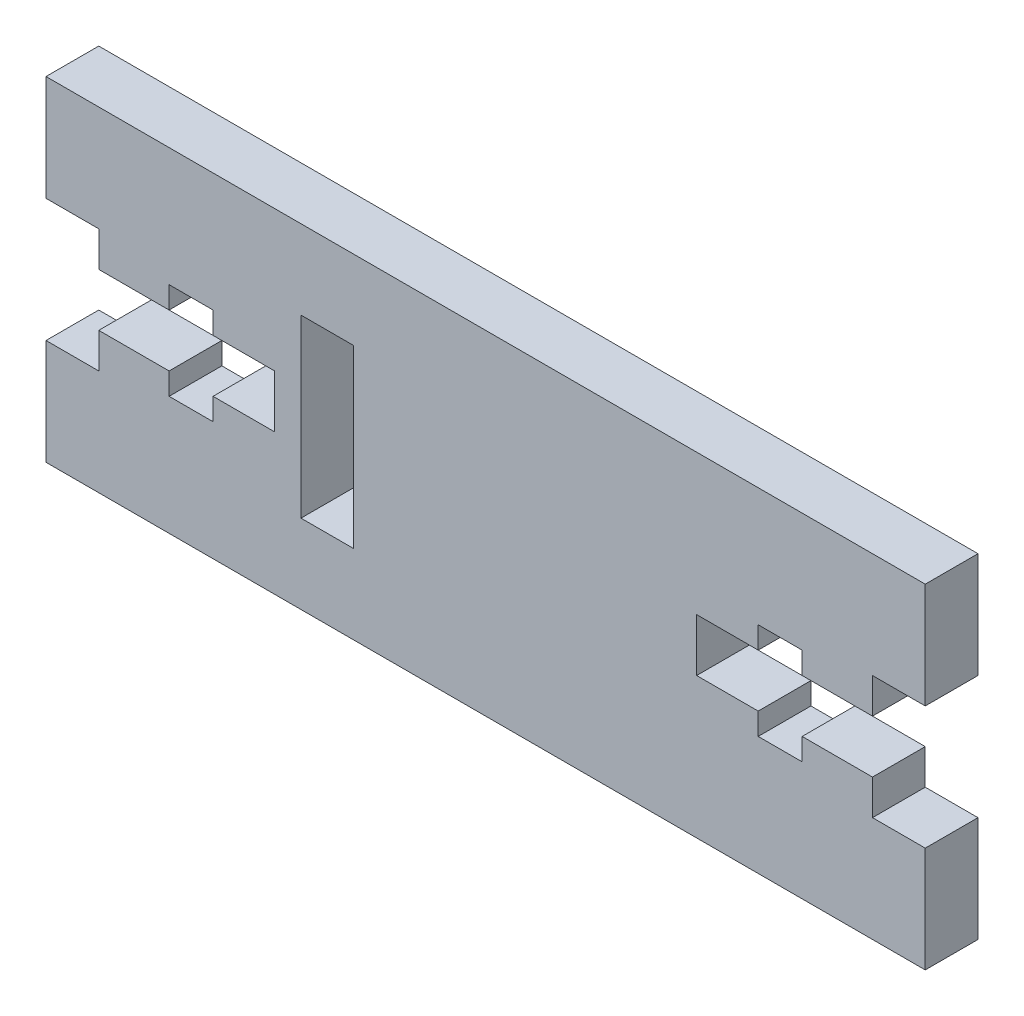
from build123d import *

# Parameters (mm, degrees)
MODEL_W             = 3
MODEL_H             = 10
BOSS_EXTRUDE1_DEPTH = 3


with BuildPart() as part:
    # Model → Boss-Extrude1 (new body)
    with BuildSketch(Plane.XY):
        Polygon((83, 32.5), (33, 32.5), (33, 38.5), (36, 38.5), (36, 40.5), (40, 40.5), (40, 39.25), (42.5, 39.25), (42.5, 40.5), (46, 40.5), (46, 43.5), (42.5, 43.5), (42.5, 44.75), (40, 44.75), (40, 43.5), (36, 43.5), (36, 45.5), (33, 45.5), (33, 51.5), (83, 51.5), (83, 45.5), (80, 45.5), (80, 43.5), (76, 43.5), (76, 44.75), (73.5, 44.75), (73.5, 43.5), (70, 43.5), (70, 40.5), (73.5, 40.5), (73.5, 39.25), (76, 39.25), (76, 40.5), (80, 40.5), (80, 38.5), (83, 38.5), align=None)
        with Locations((49, 42)):
            Rectangle(MODEL_W, MODEL_H, mode=Mode.SUBTRACT)
    extrude(amount=BOSS_EXTRUDE1_DEPTH)


solid = part.part
